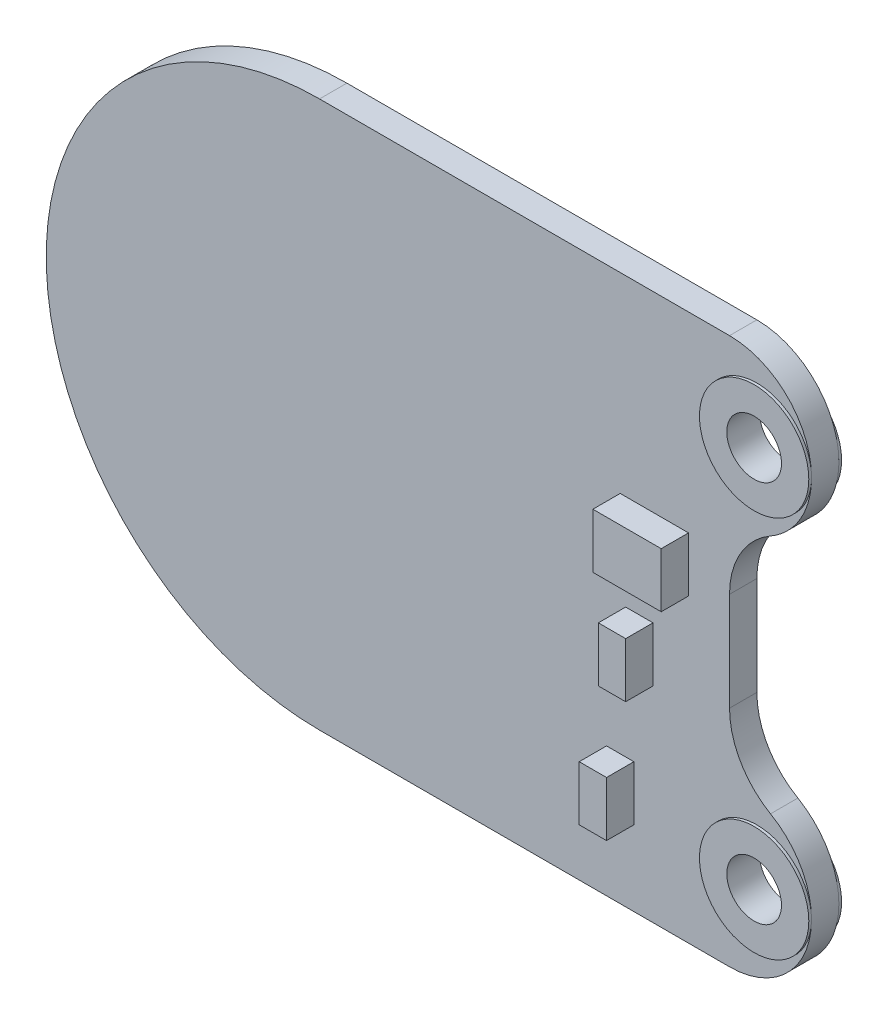
from build123d import *

# Parameters (mm, degrees)
SKETCH1_R                = 1
BOSS_EXTRUDE1_DEPTH      = 1
FILLET1_R                = 3
SKETCH2_R                = 2
BOSS_EXTRUDE2_DEPTH      = 0.1
BOSS_EXTRUDE2_DEPTH_BACK = 1.1
SKETCH3_R                = 1
CUT_EXTRUDE1_DEPTH       = 2
SKETCH4_W                = 2.5
SKETCH4_H                = 2
SKETCH4_W_2              = 1
BOSS_EXTRUDE3_DEPTH      = 1


with BuildPart() as part:
    # Sketch1 → Boss-Extrude1 (new body)
    with BuildSketch(Plane.XY):
        with BuildLine():
            Line((11, 4), (11, -4))
            ThreePointArc((11, -4), (14, -7), (11, -10))
            Line((11, -10), (-4, -10))
            ThreePointArc((-4, -10), (-14, 0), (-4, 10))
            Line((-4, 10), (11, 10))
            ThreePointArc((11, 10), (14, 7), (11, 4))
        make_face()
        with Locations((12, 7)):
            Circle(SKETCH1_R, mode=Mode.SUBTRACT)
        with Locations((12, -7)):
            Circle(SKETCH1_R, mode=Mode.SUBTRACT)
    extrude(amount=BOSS_EXTRUDE1_DEPTH)

    # Fillet1
    fillet1_edges = [part.edges().sort_by_distance(p)[0] for p in [
        (11, 4, 0.5),
        (11, -4, 0.5),
    ]]
    fillet(fillet1_edges, radius=FILLET1_R)

    # Sketch2 → Boss-Extrude2 (add, two sides)
    with BuildSketch(Plane.XY.offset(1)) as boss_extrude2_sk:
        with Locations((12, 7)):
            Circle(SKETCH2_R)
        with Locations((12, -7)):
            Circle(SKETCH2_R)
    extrude(amount=BOSS_EXTRUDE2_DEPTH)
    extrude(boss_extrude2_sk.sketch, amount=-BOSS_EXTRUDE2_DEPTH_BACK)

    # Sketch3 → Cut-Extrude1 (cut)
    with BuildSketch(Plane.XY.offset(1.1)):
        with Locations((12, 7)):
            Circle(SKETCH3_R)
        with Locations((12, -7)):
            Circle(SKETCH3_R)
    extrude(amount=-CUT_EXTRUDE1_DEPTH, mode=Mode.SUBTRACT)

    # Sketch4 → Boss-Extrude3 (add)
    with BuildSketch(Plane.XY.offset(1)):
        with Locations((8.25, 2)):
            Rectangle(SKETCH4_W, SKETCH4_H)
        with Locations((7.7, -1.5)):
            Rectangle(SKETCH4_W_2, SKETCH4_H)
        with Locations((7, -6.25)):
            Rectangle(SKETCH4_W_2, SKETCH4_H)
    extrude(amount=BOSS_EXTRUDE3_DEPTH)


solid = part.part
